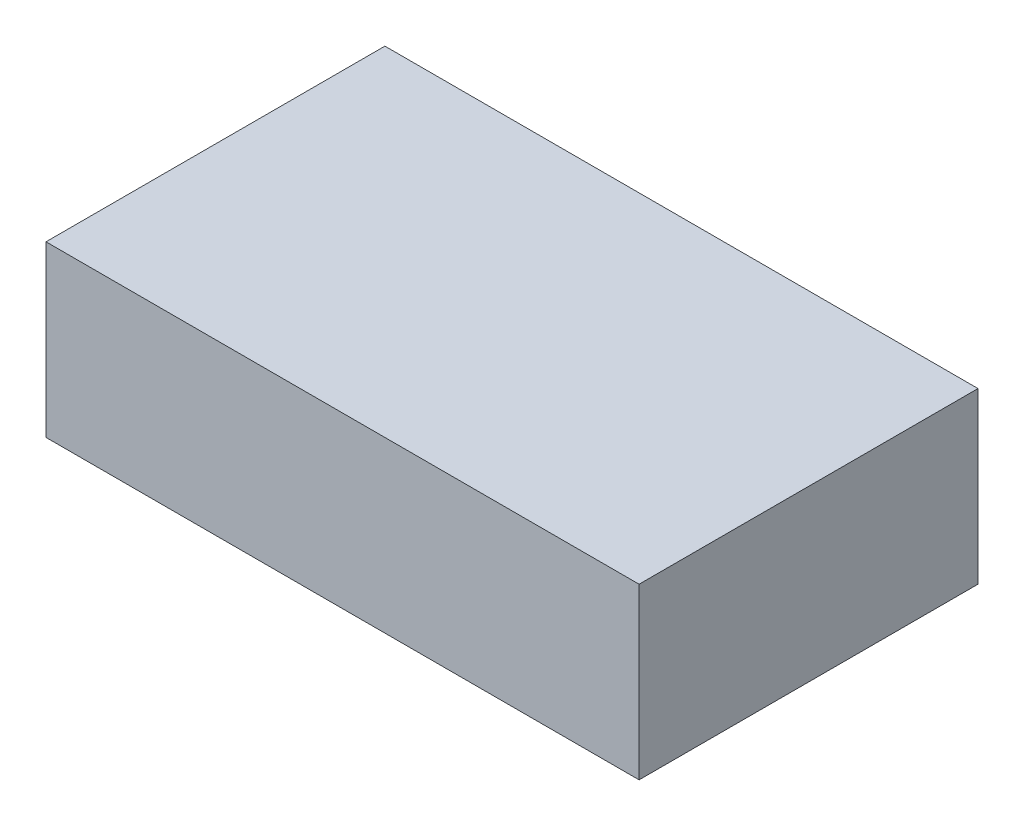
from build123d import *

# Parameters (mm, degrees)
SKETCH1_W           = 700
SKETCH1_H           = 400
BOSS_EXTRUDE1_DEPTH = 200


with BuildPart() as part:
    # Sketch1 → Boss-Extrude1 (new body)
    with BuildSketch(Plane(origin=(0, 0, 0), x_dir=(1, 0, 0), z_dir=(0, 1, 0))):
        Rectangle(SKETCH1_W, SKETCH1_H)
    extrude(amount=BOSS_EXTRUDE1_DEPTH)


solid = part.part
